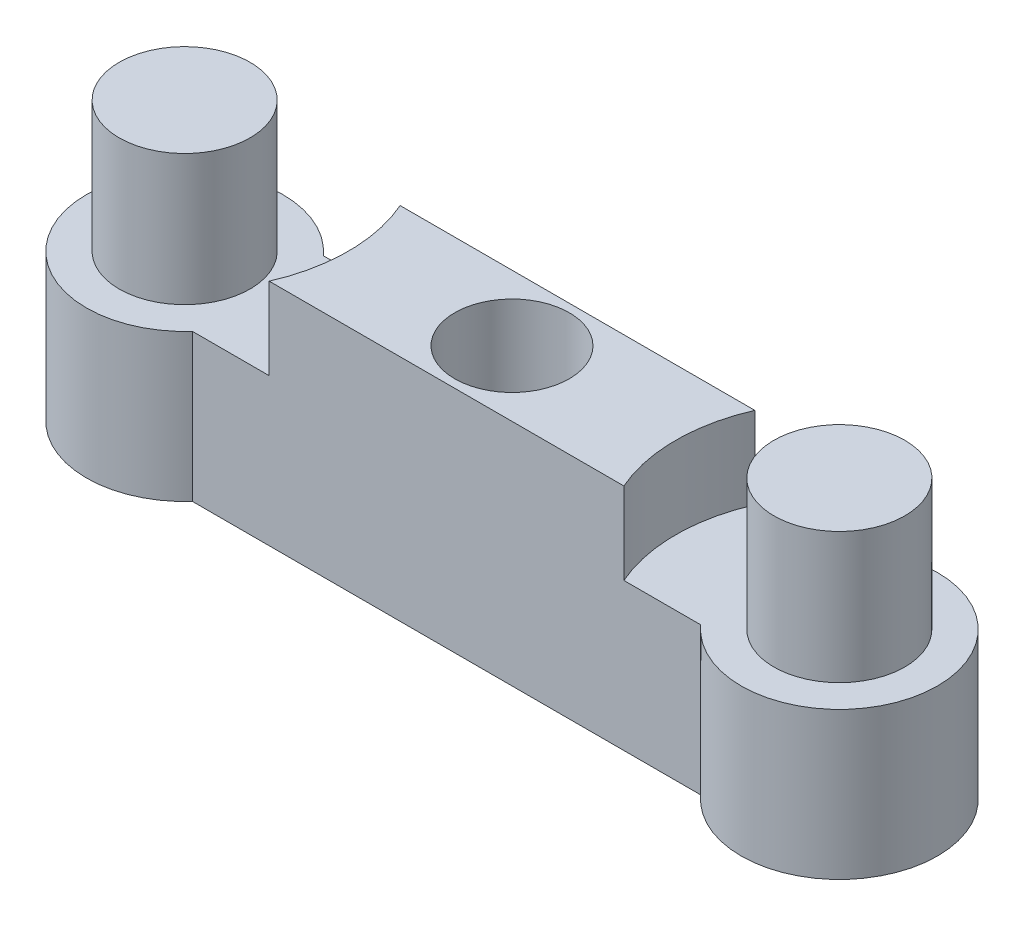
from build123d import *

# Parameters (mm, degrees)
EXTRUDE_1_DEPTH     = 9
SKETCH_2_R          = 5
CUT_EXTRUDE_1_DEPTH = 4.5
SKETCH_3_R          = 2
EXTRUDE_2_DEPTH     = 4
SKETCH_4_R          = 1
CUT_EXTRUDE_2_DEPTH = 10
SKETCH_5_R          = 1.75
CUT_EXTRUDE_3_DEPTH = 7
SKETCH_6_W          = 12.787856614
SKETCH_6_H          = 6.453658168
CUT_EXTRUDE_4_DEPTH = 2


with BuildPart() as part:
    # 草图1 → 凸台-拉伸1 (new body)
    with BuildSketch(Plane(origin=(0, 0, 0), x_dir=(1, 0, 0), z_dir=(0, 1, 0))):
        with BuildLine():
            Line((7.763932023, -2), (-7.763932023, -2))
            ThreePointArc((-7.763932023, -2), (-13, 0), (-7.763932023, 2))
            Line((-7.763932023, 2), (7.763932023, 2))
            ThreePointArc((7.763932023, 2), (13, 0), (7.763932023, -2))
        make_face()
    extrude(amount=EXTRUDE_1_DEPTH)

    # 草图2 → 切除-拉伸1 (cut)
    with BuildSketch(Plane(origin=(0, 9, 0), x_dir=(1, 0, 0), z_dir=(0, 1, 0))):
        with Locations((-10, 0)):
            Circle(SKETCH_2_R)
        with Locations((10, 0)):
            Circle(SKETCH_2_R)
    extrude(amount=-CUT_EXTRUDE_1_DEPTH, mode=Mode.SUBTRACT)

    # 草图3 → 凸台-拉伸2 (add)
    with BuildSketch(Plane(origin=(0, 4.5, 0), x_dir=(1, 0, 0), z_dir=(0, 1, 0))):
        with Locations((-10, 0)):
            Circle(SKETCH_3_R)
        with Locations((10, 0)):
            Circle(SKETCH_3_R)
    extrude(amount=EXTRUDE_2_DEPTH)

    # 草图4 → 切除-拉伸2 (cut, through all)
    with BuildSketch(Plane(origin=(0, 9, 0), x_dir=(1, 0, 0), z_dir=(0, 1, 0))):
        Circle(SKETCH_4_R)
    extrude(amount=-CUT_EXTRUDE_2_DEPTH, mode=Mode.SUBTRACT)

    # 草图5 → 切除-拉伸3 (cut)
    with BuildSketch(Plane(origin=(0, 9, 0), x_dir=(1, 0, 0), z_dir=(0, 1, 0))):
        Circle(SKETCH_5_R)
    extrude(amount=-CUT_EXTRUDE_3_DEPTH, mode=Mode.SUBTRACT)

    # 草图6 → 切除-拉伸4 (cut)
    with BuildSketch(Plane(origin=(0, 9, 0), x_dir=(1, 0, 0), z_dir=(0, 1, 0))):
        Rectangle(SKETCH_6_W, SKETCH_6_H)
    extrude(amount=-CUT_EXTRUDE_4_DEPTH, mode=Mode.SUBTRACT)


solid = part.part
